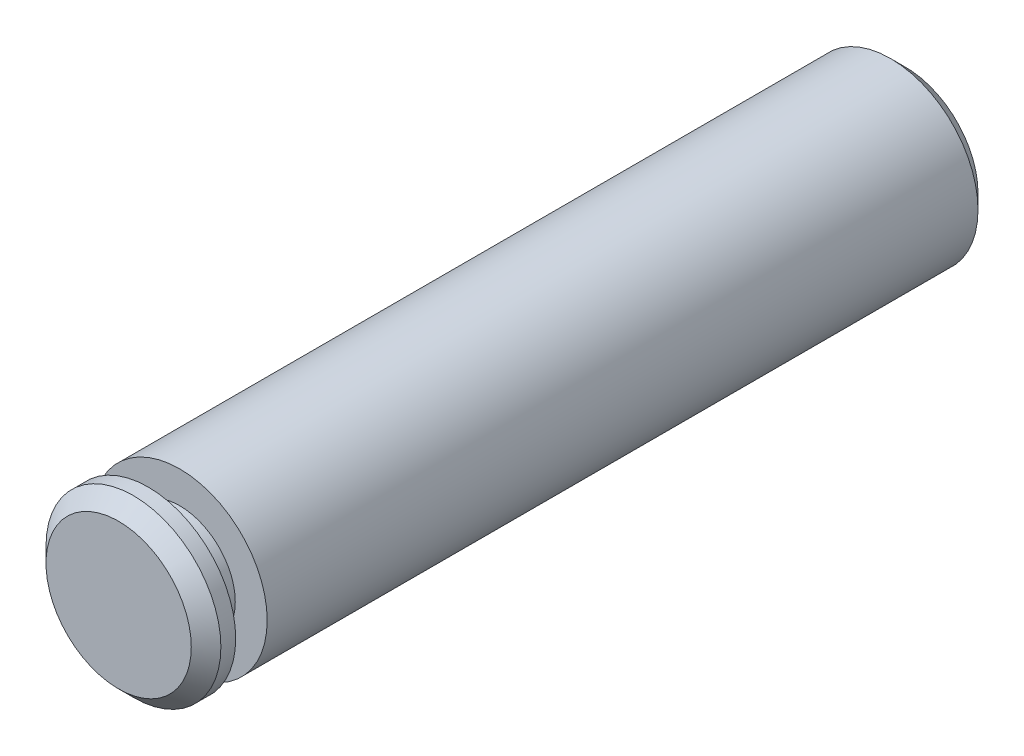
from build123d import *

# Parameters (mm, degrees)
SKETCH1_R           = 1.49987
BOSS_EXTRUDE1_DEPTH = 6.746875
SKETCH2_W           = 0.54
SKETCH2_H           = 0.54737
CHAMFER1_SIZE       = 0.254


with BuildPart() as part:
    # Sketch1 → Boss-Extrude1 (new body, symmetric)
    with BuildSketch(Plane.XY):
        Circle(SKETCH1_R)
    extrude(amount=BOSS_EXTRUDE1_DEPTH, both=True)

    # Sketch2 → Cut-Revolve1 (revolve, cut)
    with BuildSketch(Plane(origin=(0, 0, 0), x_dir=(0, 0, -1), z_dir=(1, 0, 0))):
        with Locations((-5.968875, -1.226185)):
            Rectangle(SKETCH2_W, SKETCH2_H)
    revolve(axis=Axis((0, 0, 8.828032455), (0, 0, -1)), mode=Mode.SUBTRACT)

    # Chamfer1
    chamfer1_edges = [part.edges().sort_by_distance(p)[0] for p in [
        (-1.49987, 0, -6.746875),
        (-1.49987, 0, 6.746875),
    ]]
    chamfer(chamfer1_edges, length=CHAMFER1_SIZE)


solid = part.part
